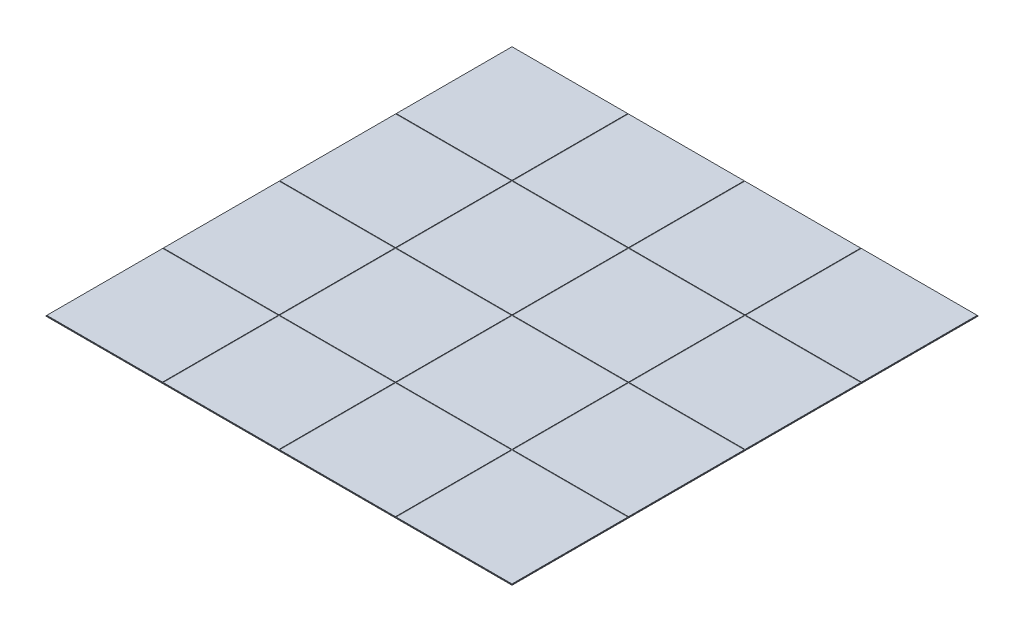
from build123d import *

# Parameters (mm, degrees)
SKETCH1_W            = 6000
SKETCH1_H            = 6000
BOSS_EXTRUDE1_DEPTH  = 10
SKETCH2_W            = 1500
SKETCH2_H            = 1500
SKETCH2_W_2          = 1490
SKETCH2_H_2          = 1490
CUT_EXTRUDE1_DEPTH   = 5
LPATTERN1_COUNT      = 4
LPATTERN1_PITCH      = 1500
LPATTERN1_COUNT_DIR2 = 4
LPATTERN1_PITCH_DIR2 = 1500


with BuildPart() as part:
    # Sketch1 → Boss-Extrude1 (new body)
    with BuildSketch(Plane(origin=(0, 0, 0), x_dir=(1, 0, 0), z_dir=(0, 1, 0))):
        Rectangle(SKETCH1_W, SKETCH1_H)
    extrude(amount=BOSS_EXTRUDE1_DEPTH)

    # Sketch2 → Cut-Extrude1 (cut)
    with BuildSketch(Plane(origin=(0, 10, 0), x_dir=(1, 0, 0), z_dir=(0, 1, 0))):
        with Locations((-2250, 2250)):
            Rectangle(SKETCH2_W, SKETCH2_H)
        with Locations((-2250, 2250)):
            Rectangle(SKETCH2_W_2, SKETCH2_H_2, mode=Mode.SUBTRACT)
    cut_extrude1 = extrude(amount=-CUT_EXTRUDE1_DEPTH, mode=Mode.SUBTRACT)

    # LPattern1: Cut-Extrude1 4 × 4
    with Locations(*[(j * LPATTERN1_PITCH_DIR2, 0, i * LPATTERN1_PITCH) for i in range(LPATTERN1_COUNT) for j in range(LPATTERN1_COUNT_DIR2) if (i, j) != (0, 0)]):
        add(cut_extrude1, mode=Mode.SUBTRACT)


solid = part.part
